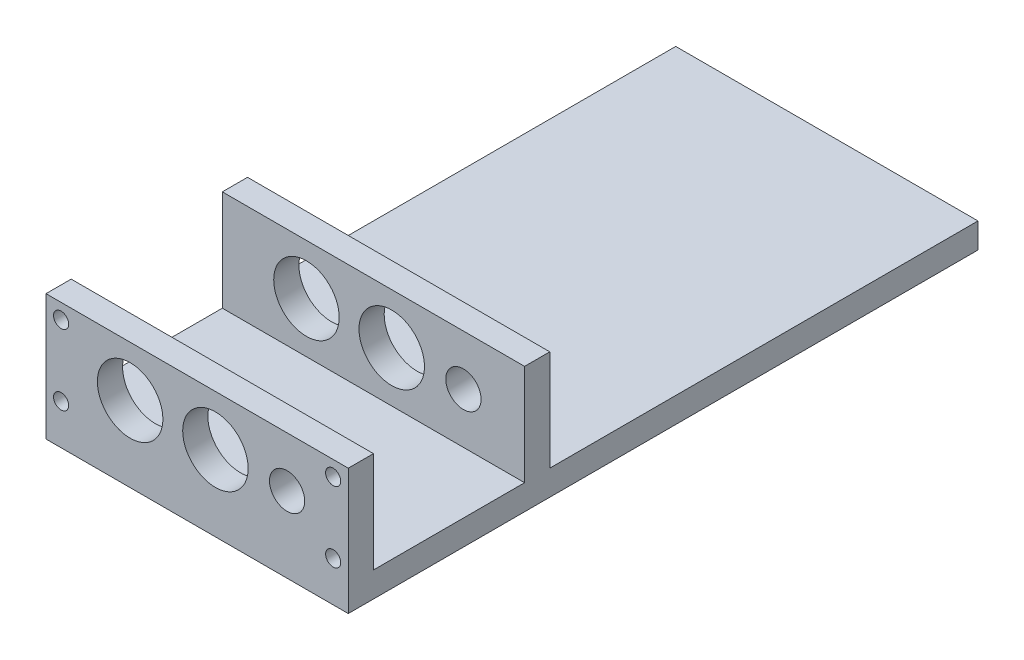
from build123d import *

# Parameters (mm, degrees)
SKETCH_1_W               = 60
SKETCH_1_H               = 25
EXTRUDE_1_DEPTH          = 5
SKETCH_2_W               = 60
SKETCH_2_H               = 5
EXTRUDE_2_DEPTH          = 120
SKETCH_3_W               = 60
SKETCH_3_H               = 5
EXTRUDE_3_DEPTH          = 20
SKETCH_4_R               = 1.5
CUT_EXTRUDE_1_DEPTH      = 20
SKETCH_5_R               = 6.5
CUT_EXTRUDE_2_DEPTH      = 121
CUT_EXTRUDE_2_DEPTH_BACK = 6
SKETCH_6_R               = 3.5
CUT_EXTRUDE_3_DEPTH      = 121
CUT_EXTRUDE_3_DEPTH_BACK = 6


with BuildPart() as part:
    # 스케치1 → 보스-돌출1 (new body)
    with BuildSketch(Plane.XY):
        with Locations((30, 12.5)):
            Rectangle(SKETCH_1_W, SKETCH_1_H)
    extrude(amount=EXTRUDE_1_DEPTH)

    # 스케치2 → 보스-돌출2 (add)
    with BuildSketch(Plane(origin=(0, 0, 0), x_dir=(-1, 0, 0), z_dir=(0, 0, -1))):
        with Locations((-30, 2.5)):
            Rectangle(SKETCH_2_W, SKETCH_2_H)
    extrude(amount=EXTRUDE_2_DEPTH)

    # 스케치3 → 보스-돌출3 (add)
    with BuildSketch(Plane(origin=(0, 5, 0), x_dir=(1, 0, 0), z_dir=(0, 1, 0))):
        with Locations((30, 32.5)):
            Rectangle(SKETCH_3_W, SKETCH_3_H)
    extrude(amount=EXTRUDE_3_DEPTH)

    # 스케치4 → 컷-돌출1 (cut)
    with BuildSketch(Plane(origin=(0, 0, 0), x_dir=(-1, 0, 0), z_dir=(0, 0, -1))):
        with Locations((-57, 22)):
            Circle(SKETCH_4_R)
        with Locations((-57, 8)):
            Circle(SKETCH_4_R)
        with Locations((-3, 22)):
            Circle(SKETCH_4_R)
        with Locations((-3, 8)):
            Circle(SKETCH_4_R)
    extrude(amount=-CUT_EXTRUDE_1_DEPTH, mode=Mode.SUBTRACT)

    # 스케치5 → 컷-돌출2 (cut, two sides)
    with BuildSketch(Plane(origin=(0, 0, 0), x_dir=(-1, 0, 0), z_dir=(0, 0, -1))) as cut_extrude_2_sk:
        with Locations((-33.62939322, 15)):
            Circle(SKETCH_5_R)
        with Locations((-16.699372841, 15)):
            Circle(SKETCH_5_R)
    extrude(amount=CUT_EXTRUDE_2_DEPTH, mode=Mode.SUBTRACT)
    extrude(cut_extrude_2_sk.sketch, amount=-CUT_EXTRUDE_2_DEPTH_BACK, mode=Mode.SUBTRACT)

    # 스케치6 → 컷-돌출3 (cut, two sides)
    with BuildSketch(Plane(origin=(0, 0, 0), x_dir=(-1, 0, 0), z_dir=(0, 0, -1))) as cut_extrude_3_sk:
        with Locations((-47.855782548, 15)):
            Circle(SKETCH_6_R)
    extrude(amount=CUT_EXTRUDE_3_DEPTH, mode=Mode.SUBTRACT)
    extrude(cut_extrude_3_sk.sketch, amount=-CUT_EXTRUDE_3_DEPTH_BACK, mode=Mode.SUBTRACT)


solid = part.part
